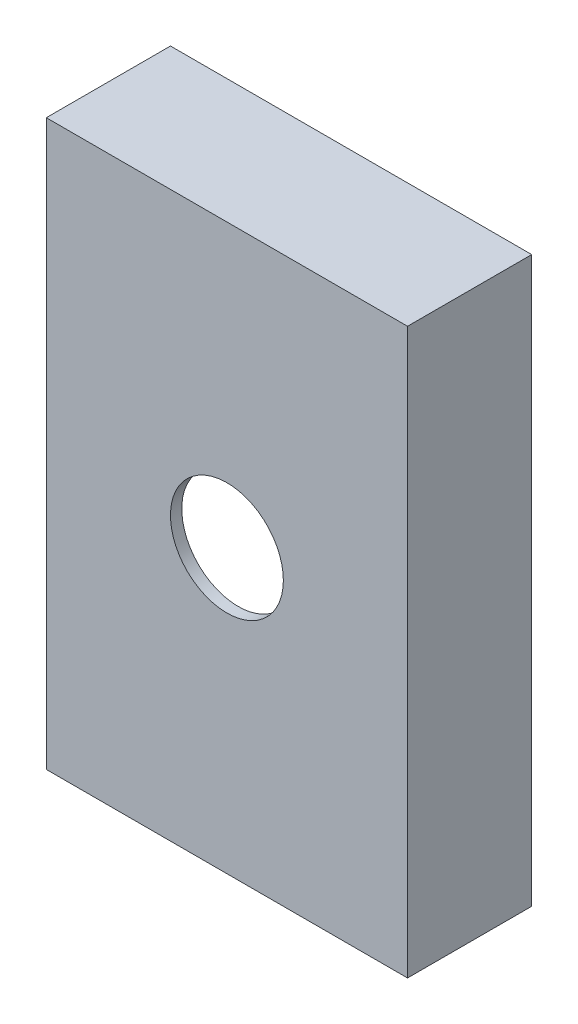
from build123d import *

# Parameters (mm, degrees)
ESQUISSE1_W             = 160
ESQUISSE1_H             = 250
ESQUISSE1_W_2           = 150
ESQUISSE1_H_2           = 240
BOSS_EXTRU_1_DEPTH      = 50
ESQUISSE2_W             = 160
ESQUISSE2_H             = 250
BOSS_EXTRU_2_DEPTH      = 5
ESQUISSE4_R             = 25
ENL_V_MAT_EXTRU_1_DEPTH = 10


with BuildPart() as part:
    # Esquisse1 → Boss.-Extru.1 (new body)
    with BuildSketch(Plane.XY):
        with Locations((-80, 125)):
            Rectangle(ESQUISSE1_W, ESQUISSE1_H)
        with Locations((-80, 125)):
            Rectangle(ESQUISSE1_W_2, ESQUISSE1_H_2, mode=Mode.SUBTRACT)
    extrude(amount=BOSS_EXTRU_1_DEPTH)

    # Esquisse2 → Boss.-Extru.2 (add)
    with BuildSketch(Plane.XY.offset(50)):
        with Locations((-80, 125)):
            Rectangle(ESQUISSE2_W, ESQUISSE2_H)
    extrude(amount=BOSS_EXTRU_2_DEPTH)

    # Esquisse4 → Enlèv. mat.-Extru.1 (cut)
    with BuildSketch(Plane.XY.offset(55)):
        with Locations((-80, 125)):
            Circle(ESQUISSE4_R)
    extrude(amount=-ENL_V_MAT_EXTRU_1_DEPTH, mode=Mode.SUBTRACT)


solid = part.part
